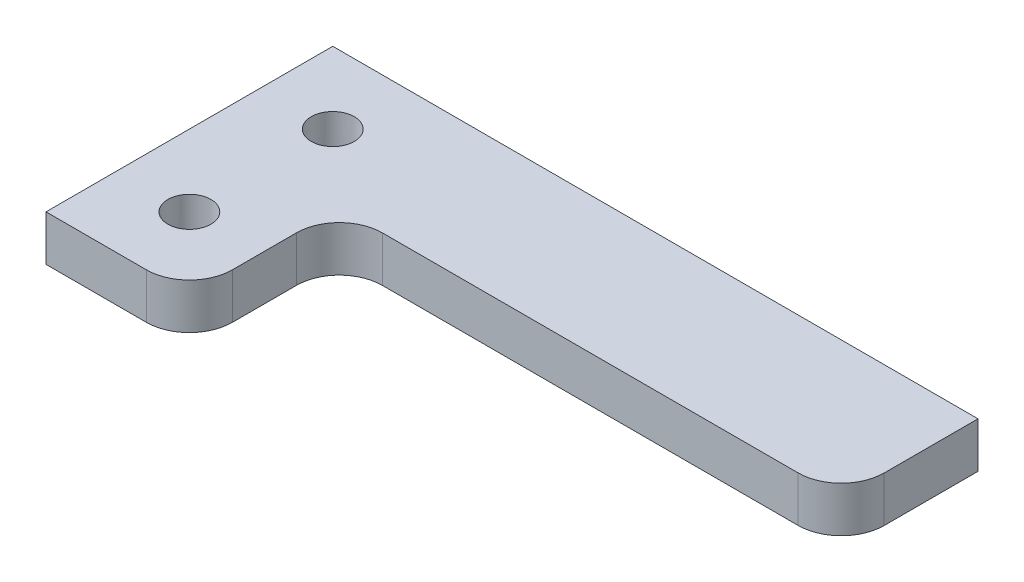
from build123d import *

# Parameters (mm, degrees)
BOSS_EXTRUDE1_DEPTH          = 3.175
F_3_0_3_DIAMETER_HOLE1_D     = 3
F_3_0_3_DIAMETER_HOLE1_DEPTH = 10
F_3_0_3_DIAMETER_HOLE1_TIP   = 0.901290929


with BuildPart() as part:
    # Sketch1 → Boss-Extrude1 (new body)
    with BuildSketch(Plane(origin=(0, 0, 0), x_dir=(1, 0, 0), z_dir=(0, 1, 0))):
        with BuildLine():
            Line((0, 0), (45, 0))
            Line((45, 0), (45, -6.539392014))
            ThreePointArc((45, -6.539392014), (44.121320344, -8.660712358), (42, -9.539392014))
            Line((42, -9.539392014), (13, -9.539392014))
            ThreePointArc((13, -9.539392014), (10.878679656, -10.418071671), (10, -12.539392014))
            Line((10, -12.539392014), (10, -17))
            ThreePointArc((10, -17), (9.121320344, -19.121320344), (7, -20))
            Line((7, -20), (0, -20))
            Line((0, -20), (0, 0))
        make_face()
    extrude(amount=BOSS_EXTRUDE1_DEPTH)

    # Ø3.0 (3) Diameter Hole1
    with Locations(Plane(origin=(0, 3.175, 0), x_dir=(-1, 0, 0), z_dir=(0, 1, 0))):
        with Locations((-5, 5), (-5, 15)):
            Hole(F_3_0_3_DIAMETER_HOLE1_D / 2, depth=F_3_0_3_DIAMETER_HOLE1_DEPTH)
            with Locations((0, 0, -(F_3_0_3_DIAMETER_HOLE1_DEPTH + F_3_0_3_DIAMETER_HOLE1_TIP / 2))):  # 118° drill point
                Cone(0, F_3_0_3_DIAMETER_HOLE1_D / 2, F_3_0_3_DIAMETER_HOLE1_TIP, mode=Mode.SUBTRACT)


solid = part.part
